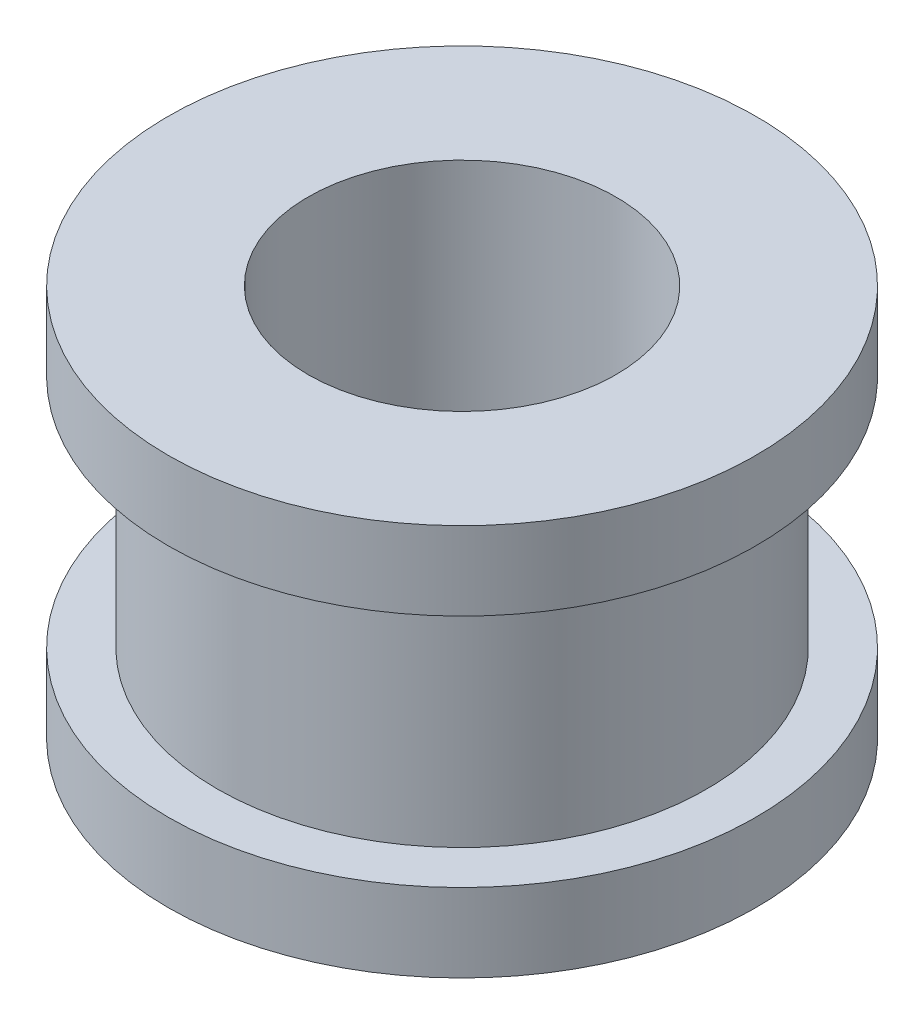
from build123d import *

# Parameters (mm, degrees)
SKETCH1_R           = 4.7625
SKETCH1_R_2         = 2.49555
BOSS_EXTRUDE1_DEPTH = 6.35
CUT_EXTRUDE1_START  = -5.08
SKETCH2_R           = 4.7625
SKETCH2_R_2         = 3.96875
CUT_EXTRUDE1_DEPTH  = 3.81


with BuildPart() as part:
    # Sketch1 → Boss-Extrude1 (new body)
    with BuildSketch(Plane(origin=(0, 0, 0), x_dir=(1, 0, 0), z_dir=(0, 1, 0))):
        Circle(SKETCH1_R)
        Circle(SKETCH1_R_2, mode=Mode.SUBTRACT)
    extrude(amount=BOSS_EXTRUDE1_DEPTH)

    # Sketch2 → Cut-Extrude1 (cut)
    with BuildSketch(Plane(origin=(0, 6.35, 0), x_dir=(1, 0, 0), z_dir=(0, 1, 0)).offset(CUT_EXTRUDE1_START)):
        Circle(SKETCH2_R)
        Circle(SKETCH2_R_2, mode=Mode.SUBTRACT)
    extrude(amount=CUT_EXTRUDE1_DEPTH, mode=Mode.SUBTRACT)


solid = part.part
